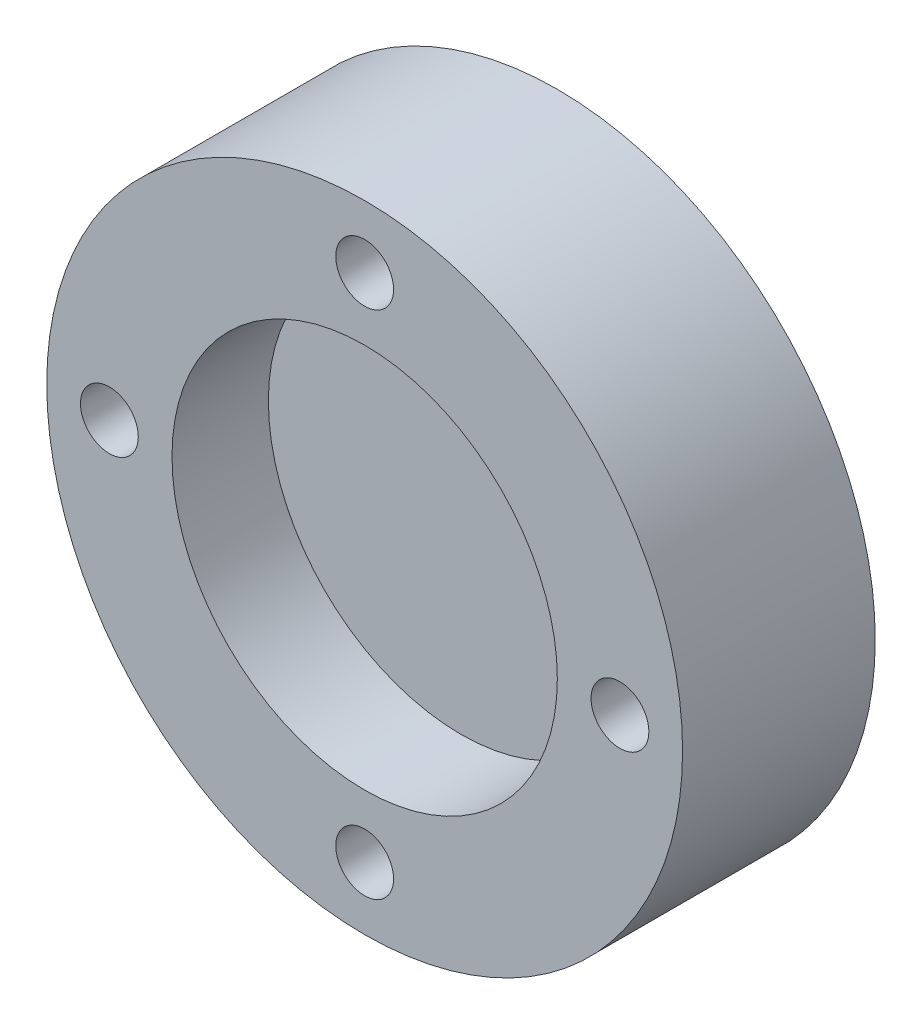
from build123d import *

# Parameters (mm, degrees)
IZIM1_R                     = 16.5
IZIM1_R_2                   = 10
IZIM1_R_3                   = 1.5
Y_KSEKLIK_EKSTR_ZYON1_DEPTH = 10
IZIM2_R                     = 9.998006204
Y_KSEKLIK_EKSTR_ZYON2_DEPTH = 5
IZIM4_R                     = 9.998006204
Y_KSEKLIK_EKSTR_ZYON3_DEPTH = 2


with BuildPart() as part:
    # Çizim1 → Yükseklik-Ekstrüzyon1 (new body)
    with BuildSketch(Plane.XY):
        Circle(IZIM1_R)
        Circle(IZIM1_R_2, mode=Mode.SUBTRACT)
        with Locations((0, 13.25)):
            Circle(IZIM1_R_3, mode=Mode.SUBTRACT)
        with Locations((13.25, 0)):
            Circle(IZIM1_R_3, mode=Mode.SUBTRACT)
        with Locations((0, -13.25)):
            Circle(IZIM1_R_3, mode=Mode.SUBTRACT)
        with Locations((-13.25, 0)):
            Circle(IZIM1_R_3, mode=Mode.SUBTRACT)
    extrude(amount=-Y_KSEKLIK_EKSTR_ZYON1_DEPTH)


with BuildPart() as body_2:
    # Çizim2 → Yükseklik-Ekstrüzyon2 (new body)
    with BuildSketch(Plane(origin=(0, 0, -10), x_dir=(-1, 0, 0), z_dir=(0, 0, -1))):
        Circle(IZIM2_R)
    extrude(amount=-Y_KSEKLIK_EKSTR_ZYON2_DEPTH)

    # Çizim4 → Yükseklik-Ekstrüzyon3 (add)
    with BuildSketch(Plane(origin=(0, 0, -10), x_dir=(-1, 0, 0), z_dir=(0, 0, -1))):
        Circle(IZIM4_R)
    extrude(amount=Y_KSEKLIK_EKSTR_ZYON3_DEPTH)


solid = Compound([part.part, body_2.part])
